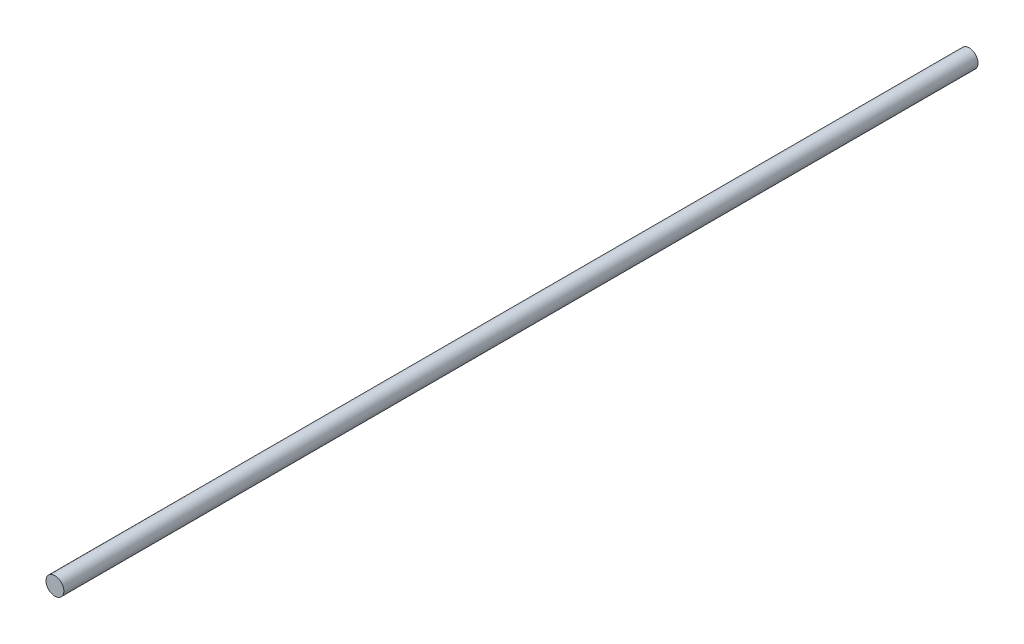
from build123d import *

# Parameters (mm, degrees)
CROQUIS1_R              = 4
SALIENTE_EXTRUIR2_DEPTH = 410


with BuildPart() as part:
    # Croquis1 → Saliente-Extruir2 (new body)
    with BuildSketch(Plane.XY):
        Circle(CROQUIS1_R)
    extrude(amount=SALIENTE_EXTRUIR2_DEPTH)


solid = part.part
